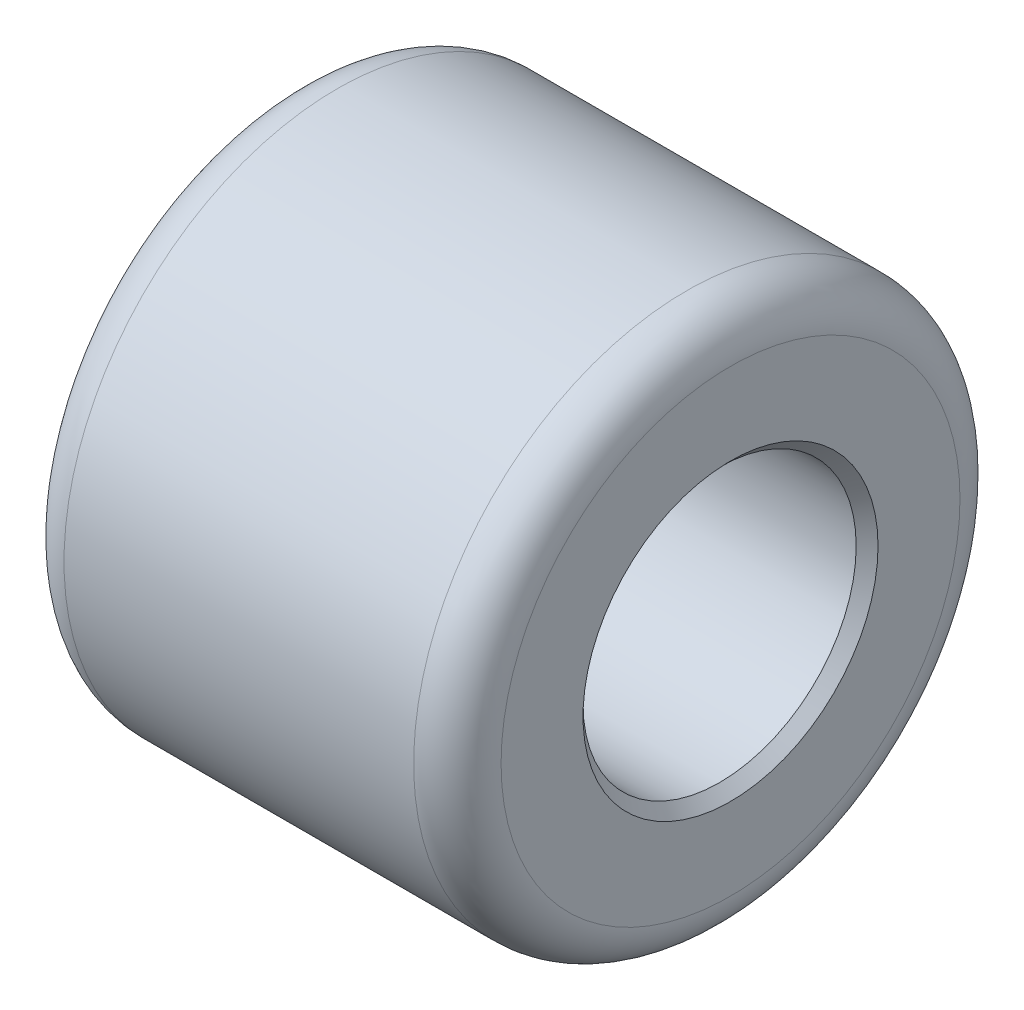
from build123d import *

# Parameters (mm, degrees)
SKETCH1_R           = 312.5
SKETCH1_R_2         = 156.25
BOSS_EXTRUDE1_DEPTH = 500
CHAMFER1_SIZE       = 12.5
FILLET1_R           = 50


with BuildPart() as part:
    # Sketch1 → Boss-Extrude1 (new body)
    with BuildSketch(Plane(origin=(0, 0, 0), x_dir=(0, 0, -1), z_dir=(1, 0, 0))):
        Circle(SKETCH1_R)
        Circle(SKETCH1_R_2, mode=Mode.SUBTRACT)
    extrude(amount=BOSS_EXTRUDE1_DEPTH)

    # Chamfer1
    chamfer1_edges = [part.edges().sort_by_distance(p)[0] for p in [
        (0, 0, 156.25),
        (500, 0, 156.25),
    ]]
    chamfer(chamfer1_edges, length=CHAMFER1_SIZE)

    # Fillet1
    fillet1_edges = [part.edges().sort_by_distance(p)[0] for p in [
        (0, 0, 312.5),
        (500, 0, 312.5),
    ]]
    fillet(fillet1_edges, radius=FILLET1_R)


solid = part.part
